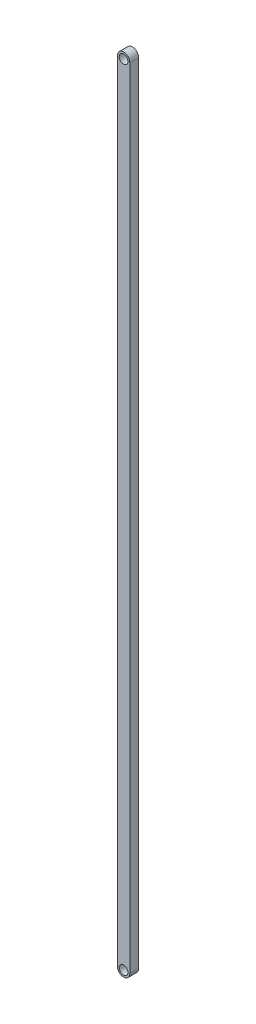
from build123d import *

# Parameters (mm, degrees)
SKETCH2_R           = 2.5
BOSS_EXTRUDE1_DEPTH = 2.5


with BuildPart() as part:
    # Sketch2 → Boss-Extrude1 (new body, symmetric)
    with BuildSketch(Plane.XY):
        with BuildLine():
            Line((3.5, 0), (3.5, -448))
            ThreePointArc((3.5, -448), (0, -451.5), (-3.5, -448))
            Line((-3.5, -448), (-3.5, 0))
            ThreePointArc((-3.5, 0), (0, 3.5), (3.5, 0))
        make_face()
        Circle(SKETCH2_R, mode=Mode.SUBTRACT)
        with Locations((0, -448)):
            Circle(SKETCH2_R, mode=Mode.SUBTRACT)
    extrude(amount=BOSS_EXTRUDE1_DEPTH, both=True)


solid = part.part
